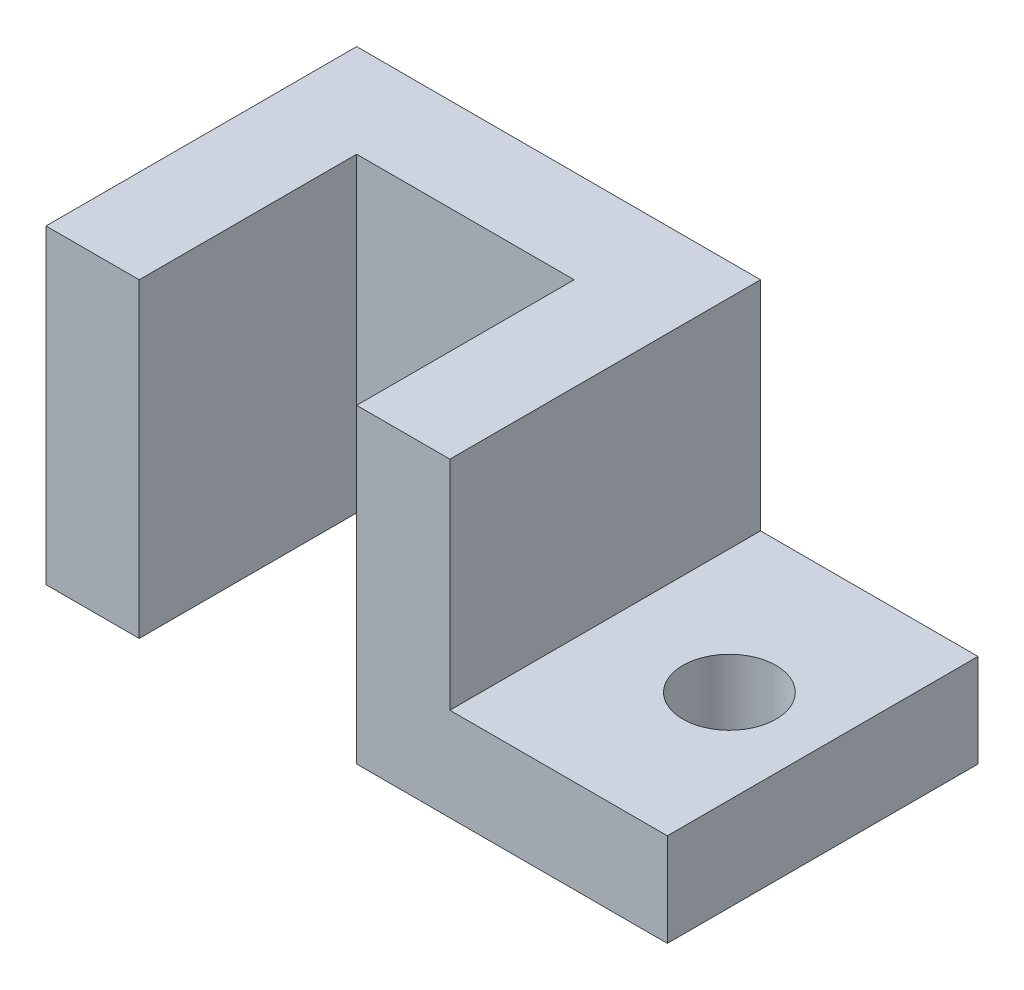
from build123d import *

# Parameters (mm, degrees)
BOSS_EXTRUDE1_DEPTH = 63.5
BOSS_EXTRUDE2_DEPTH = 63.5
SKETCH7_R           = 9.525
CUT_EXTRUDE1_DEPTH  = 20.05


with BuildPart() as part:
    # Sketch1 → Boss-Extrude1 (new body)
    with BuildSketch(Plane.XY):
        Polygon((0, 0), (63.5, 0), (63.5, 19.05), (19.05, 19.05), (19.05, 63.5), (0, 63.5), align=None)
    extrude(amount=BOSS_EXTRUDE1_DEPTH)

    # Sketch2 → Boss-Extrude2 (add)
    with BuildSketch(Plane(origin=(0, 63.5, 0), x_dir=(1, 0, 0), z_dir=(0, 1, 0))):
        Polygon((0, 0), (-63.5, 0), (-63.5, -63.5), (-44.45, -63.5), (-44.45, -19.05), (0, -19.05), align=None)
    extrude(amount=-BOSS_EXTRUDE2_DEPTH)

    # Sketch7 → Cut-Extrude1 (cut, through all)
    with BuildSketch(Plane(origin=(0, 19.05, 0), x_dir=(1, 0, 0), z_dir=(0, 1, 0))):
        with Locations(Location((44.440930772, -31.75, 0), (0, 0, 180))):  # turned: the seam where the file's is
            Circle(SKETCH7_R)
    extrude(amount=-CUT_EXTRUDE1_DEPTH, mode=Mode.SUBTRACT)


solid = part.part
